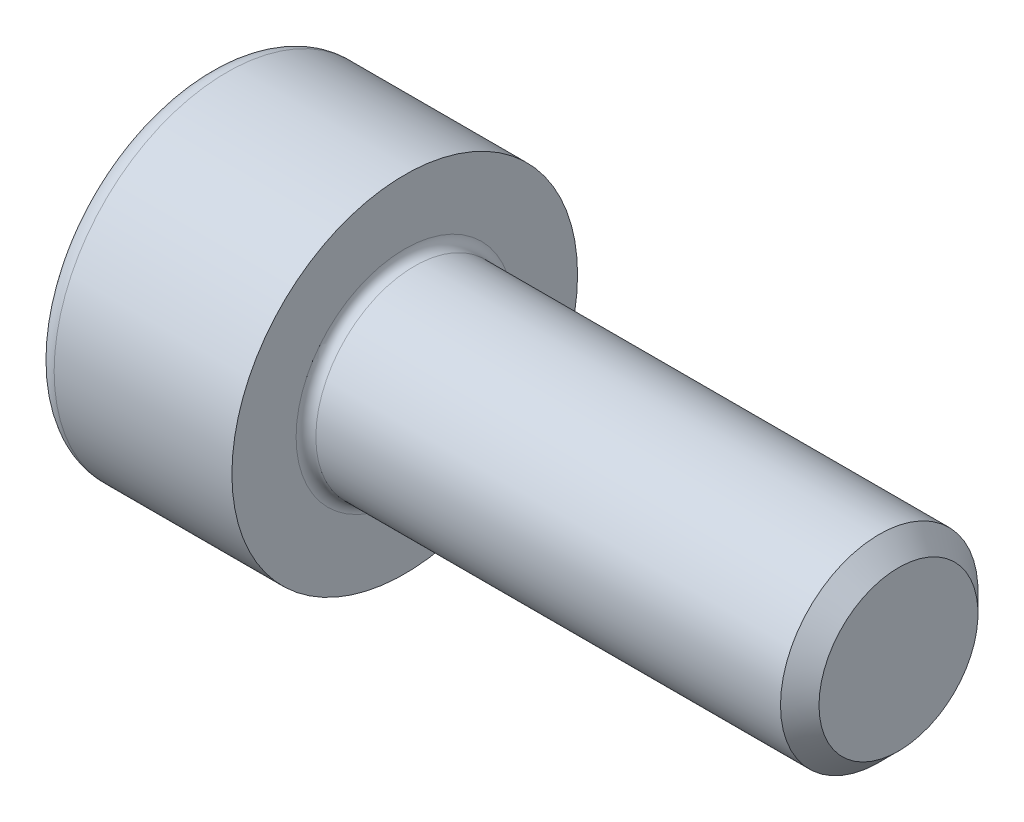
from build123d import *

# Parameters (mm, degrees)
FILLET1_R   = 0.2
FILLET2_R   = 0.4
HEX_2_DEPTH = 2


with BuildPart() as part:
    # BodySke → Base-Revolve (revolve)
    with BuildSketch(Plane.XY):
        Polygon((0, 0), (0, 3.5), (4, 3.5), (4, 2), (13.61, 2), (14, 1.61), (14, 0), align=None)
    revolve(axis=Axis((-31.75, 0, 0), (1, 0, 0)))

    # Fillet1
    fillet1_edges = [part.edges().sort_by_distance(p)[0] for p in [
        (4, -2, 0),
    ]]
    fillet(fillet1_edges, radius=FILLET1_R)

    # Fillet2
    fillet2_edges = [part.edges().sort_by_distance(p)[0] for p in [
        (0, -3.5, 0),
    ]]
    fillet(fillet2_edges, radius=FILLET2_R)

    # Sketch2 → Hex-PreBroach (revolve, cut)
    with BuildSketch(Plane.XY):
        Polygon((0, 1.51), (2, 1.51), (2.871798906, 0), (0, 0), align=None)
    revolve(axis=Axis((0, 0, 0), (1, 0, 0)), mode=Mode.SUBTRACT)

    # Sketch3 → Hex 2 (cut)
    with BuildSketch(Plane(origin=(0, 0, 0), x_dir=(0, 0.5, 0.866025404), z_dir=(-1, 0, 0))):
        Polygon((0.871798906, 1.51), (-0.871798906, 1.51), (-1.743597813, 0), (-0.871798906, -1.51), (0.871798906, -1.51), (1.743597813, 0), align=None)
    extrude(amount=-HEX_2_DEPTH, mode=Mode.SUBTRACT)


solid = part.part
